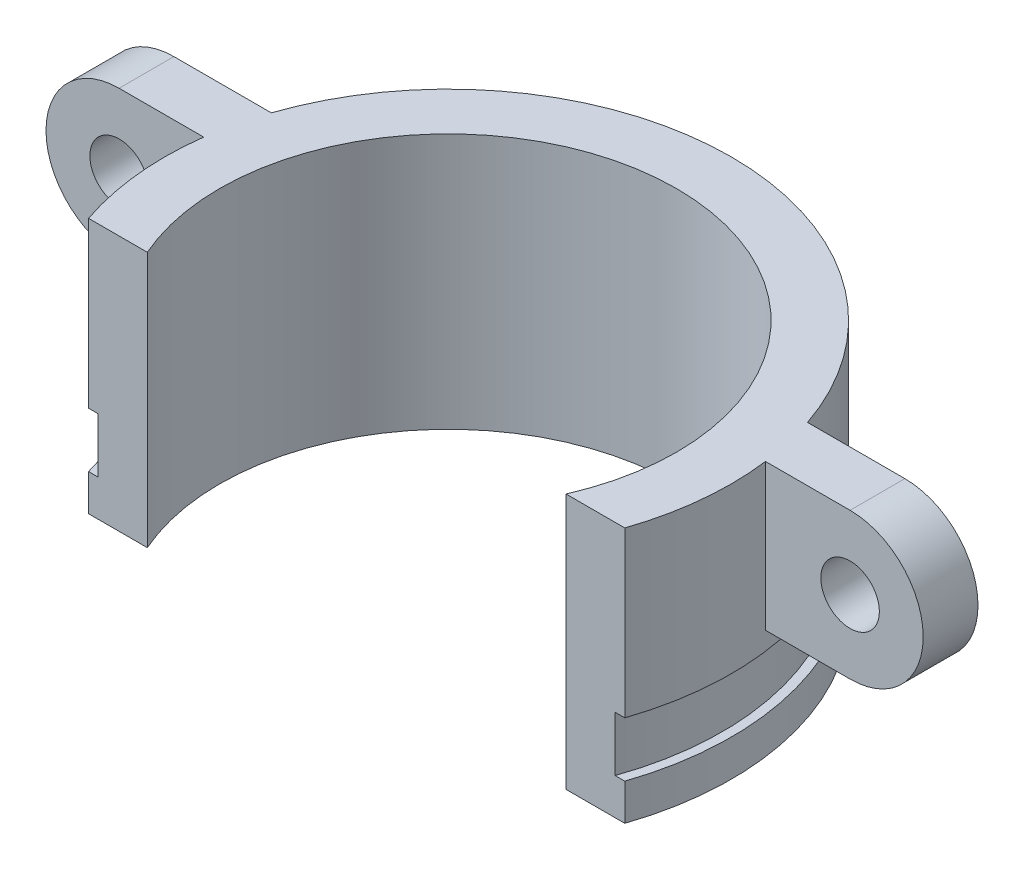
from build123d import *

# Parameters (mm, degrees)
CORTE_EXTRUS_O1_DEPTH      = 1
CORTE_EXTRUS_O1_DEPTH_BACK = 51
RESSALTO_EXTRUS_O1_START   = -2
ESBO_O3_R                  = 1.6
RESSALTO_EXTRUS_O1_DEPTH   = 3
ESBO_O4_W                  = 67.372166219
ESBO_O4_H                  = 55.074072385
ESBO_O4_W_2                = 51.598524128
ESBO_O4_H_2                = 14
CORTE_EXTRUS_O2_DEPTH      = 6
CORTE_EXTRUS_O2_DEPTH_BACK = 16.5


with BuildPart() as part:
    # Esboço1 → Revolução1 (revolve)
    with BuildSketch(Plane.XY):
        Polygon((15, 37), (15.5, 37), (15.5, 13), (15, 13), (15, 10), (15.5, 10), (15.5, 0), (12.5, 0), (12.5, 50), (15.5, 50), (15.5, 40), (15, 40), align=None)
    revolve(axis=Axis((0, 0, 0), (0, 1, 0)))

    # Esboço2 → Corte-extrusão1 (cut, two sides)
    with BuildSketch(Plane(origin=(0, 50, 0), x_dir=(1, 0, 0), z_dir=(0, 1, 0))) as corte_extrus_o1_sk:
        with BuildLine():
            Line((-11.456439237, -5), (-14.671400751, -5))
            ThreePointArc((-14.671400751, -5), (0, -15.5), (14.671400751, -5))
            Line((14.671400751, -5), (11.456439237, -5))
            ThreePointArc((11.456439237, -5), (0, -12.5), (-11.456439237, -5))
        make_face()
    extrude(amount=CORTE_EXTRUS_O1_DEPTH, mode=Mode.SUBTRACT)
    extrude(corte_extrus_o1_sk.sketch, amount=-CORTE_EXTRUS_O1_DEPTH_BACK, mode=Mode.SUBTRACT)

    # Esboço3 → Ressalto-extrusão1 (add)
    with BuildSketch(Plane.XY.offset(RESSALTO_EXTRUS_O1_START)):
        with BuildLine():
            Line((-13.5, 49), (-20, 49))
            ThreePointArc((-20, 49), (-24, 45), (-20, 41))
            Line((-20, 41), (-13.5, 41))
            Line((-13.5, 41), (-13.5, 49))
        make_face()
        with Locations((-20, 45)):
            Circle(ESBO_O3_R, mode=Mode.SUBTRACT)
        with BuildLine():
            Line((13.5, 41), (13.5, 49))
            Line((13.5, 49), (20, 49))
            ThreePointArc((20, 49), (24, 45), (20, 41))
            Line((20, 41), (13.5, 41))
        make_face()
        with Locations((20, 45)):
            Circle(ESBO_O3_R, mode=Mode.SUBTRACT)
        with BuildLine():
            Line((13.5, 1), (20, 1))
            ThreePointArc((20, 1), (24, 5), (20, 9))
            Line((20, 9), (13.5, 9))
            Line((13.5, 9), (13.5, 1))
        make_face()
        with Locations((20, 5)):
            Circle(ESBO_O3_R, mode=Mode.SUBTRACT)
        with BuildLine():
            Line((-13.5, 9), (-13.5, 1))
            Line((-13.5, 1), (-20, 1))
            ThreePointArc((-20, 1), (-24, 5), (-20, 9))
            Line((-20, 9), (-13.5, 9))
        make_face()
        with Locations((-20, 5)):
            Circle(ESBO_O3_R, mode=Mode.SUBTRACT)
    extrude(amount=-RESSALTO_EXTRUS_O1_DEPTH)

    # Esboço4 → Corte-extrusão2 (cut, two sides)
    with BuildSketch(Plane.XY) as corte_extrus_o2_sk:
        with Locations((0.066837467, 24.799487601)):
            Rectangle(ESBO_O4_W, ESBO_O4_H)
        with Locations((0, 42)):
            Rectangle(ESBO_O4_W_2, ESBO_O4_H_2, mode=Mode.SUBTRACT)
    extrude(amount=CORTE_EXTRUS_O2_DEPTH, mode=Mode.SUBTRACT)
    extrude(corte_extrus_o2_sk.sketch, amount=-CORTE_EXTRUS_O2_DEPTH_BACK, mode=Mode.SUBTRACT)


solid = part.part
